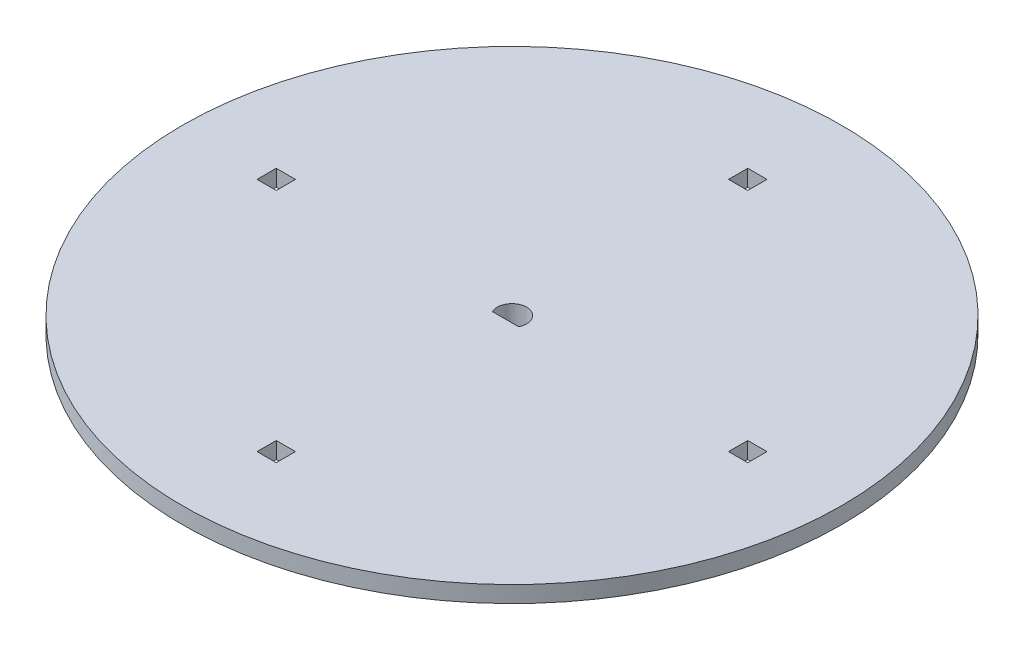
from build123d import *

# Parameters (mm, degrees)
SKETCH2_W          = 3.5
SKETCH2_H          = 3.5
CUT_EXTRUDE1_DEPTH = 8.1086


with BuildPart() as part:
    # Sketch1 → Revolve1 (revolve)
    with BuildSketch(Plane.XY):
        Polygon((1.957910998, 0), (0, 0), (0, -2.01497422), (0, -7.1086), (3.0734, -7.1086), (3.0734, -3), (60, -3), (60, 0), align=None)
    revolve(axis=Axis((0, 0, 0), (0, -1, 0)))

    # Sketch2 → Cut-Extrude1 (cut, through all)
    with BuildSketch(Plane(origin=(0, 0, 0), x_dir=(1, 0, 0), z_dir=(0, 1, 0))):
        with BuildLine():
            Line((2.37773001, -1.17), (-2.37773001, -1.17))
            ThreePointArc((-2.37773001, -1.17), (0, 2.65), (2.37773001, -1.17))
        make_face()
        with Locations((-42.92, 0)):
            Rectangle(SKETCH2_W, SKETCH2_H)
        with Locations((0, -42.92)):
            Rectangle(SKETCH2_W, SKETCH2_H)
        with Locations((0, 42.92)):
            Rectangle(SKETCH2_W, SKETCH2_H)
        with Locations((42.92, 0)):
            Rectangle(SKETCH2_W, SKETCH2_H)
    extrude(amount=-CUT_EXTRUDE1_DEPTH, mode=Mode.SUBTRACT)


solid = part.part
